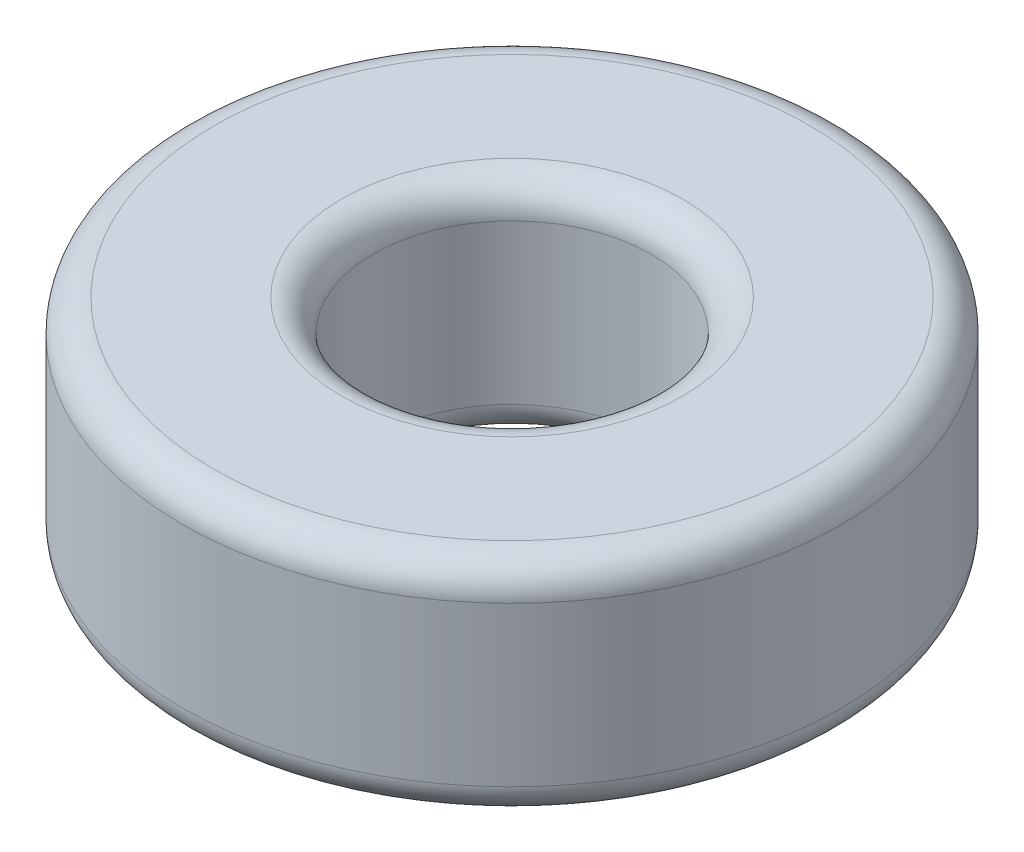
from build123d import *

# Parameters (mm, degrees)
SKETCH1_R           = 5.1844
SKETCH1_R_2         = 2.1844
BOSS_EXTRUDE1_DEPTH = 3.5
FILLET1_R           = 0.5


with BuildPart() as part:
    # Sketch1 → Boss-Extrude1 (new body)
    with BuildSketch(Plane(origin=(0, 0, 0), x_dir=(1, 0, 0), z_dir=(0, 1, 0))):
        Circle(SKETCH1_R)
        Circle(SKETCH1_R_2, mode=Mode.SUBTRACT)
    extrude(amount=BOSS_EXTRUDE1_DEPTH)

    # Fillet1
    fillet1_edges = [part.edges().sort_by_distance(p)[0] for p in [
        (-5.1844, 0, 0),
        (-5.1844, 3.5, 0),
        (-2.1844, 0, 0),
        (-2.1844, 3.5, 0),
    ]]
    fillet(fillet1_edges, radius=FILLET1_R)


solid = part.part
